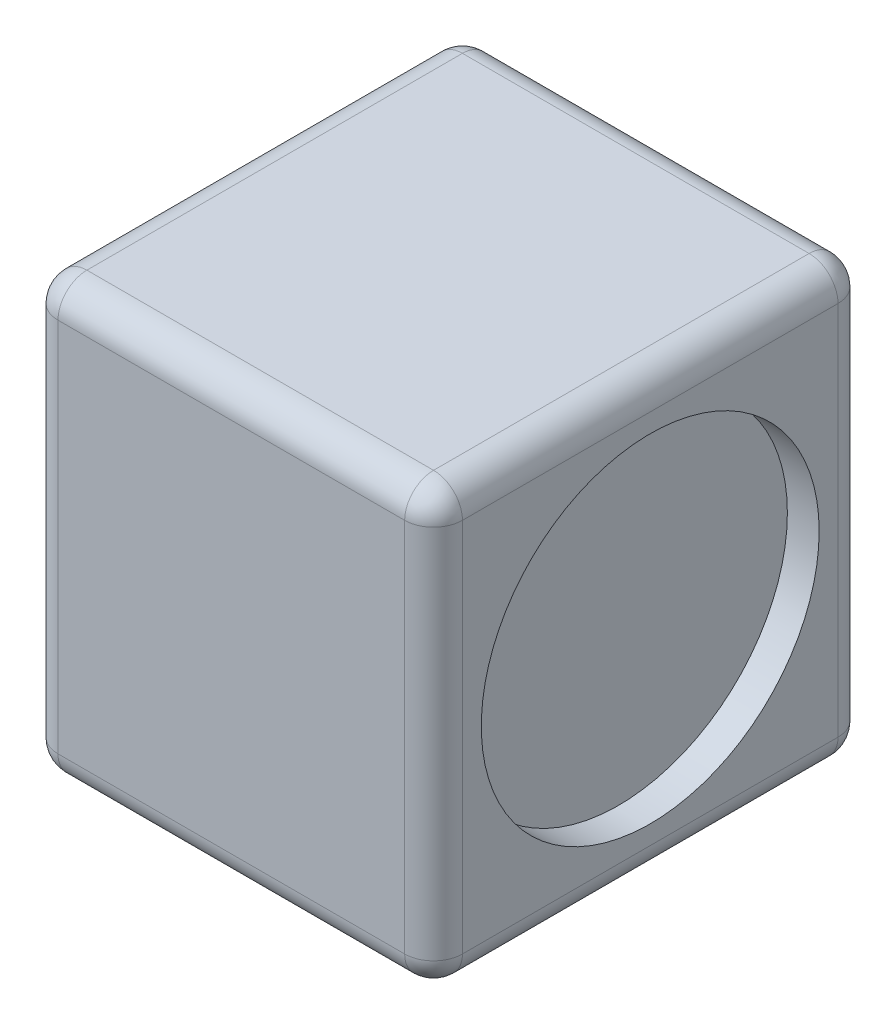
from build123d import *

# Parameters (mm, degrees)
SKETCH1_W           = 35.56
SKETCH1_H           = 38.1
BOSS_EXTRUDE1_DEPTH = 38.1
FILLET1_R           = 2.54
SKETCH4_R           = 14.853609937
CUT_EXTRUDE2_DEPTH  = 2.794
SKETCH5_W           = 6.35
SKETCH5_H           = 12.7
BOSS_EXTRUDE2_DEPTH = 1.27


with BuildPart() as part:
    # Sketch1 → Boss-Extrude1 (new body)
    with BuildSketch(Plane(origin=(0, 0, 0), x_dir=(1, 0, 0), z_dir=(0, 1, 0))):
        Rectangle(SKETCH1_W, SKETCH1_H)
    extrude(amount=BOSS_EXTRUDE1_DEPTH)

    # Fillet1
    fillet1_edges = [part.edges().sort_by_distance(p)[0] for p in [
        (17.78, 19.05, -19.05),
        (-17.78, 19.05, -19.05),
        (-17.78, 19.05, 19.05),
        (17.78, 19.05, 19.05),
        (0, 38.1, 19.05),
        (-17.78, 38.1, 0),
        (0, 38.1, -19.05),
        (17.78, 38.1, 0),
        (0, 0, -19.05),
        (-17.78, 0, 0),
        (0, 0, 19.05),
        (17.78, 0, 0),
    ]]
    fillet(fillet1_edges, radius=FILLET1_R)

    # Sketch4 → Cut-Extrude2 (cut)
    with BuildSketch(Plane(origin=(17.78, 0, 0), x_dir=(0, 0, -1), z_dir=(1, 0, 0))):
        with Locations((0, 19.05)):
            Circle(SKETCH4_R)
    extrude(amount=-CUT_EXTRUDE2_DEPTH, mode=Mode.SUBTRACT)

    # Sketch5 → Boss-Extrude2 (add)
    with BuildSketch(Plane.XZ):
        with Locations((-5.715, 0)):
            Rectangle(SKETCH5_W, SKETCH5_H)
    extrude(amount=BOSS_EXTRUDE2_DEPTH)


solid = part.part
